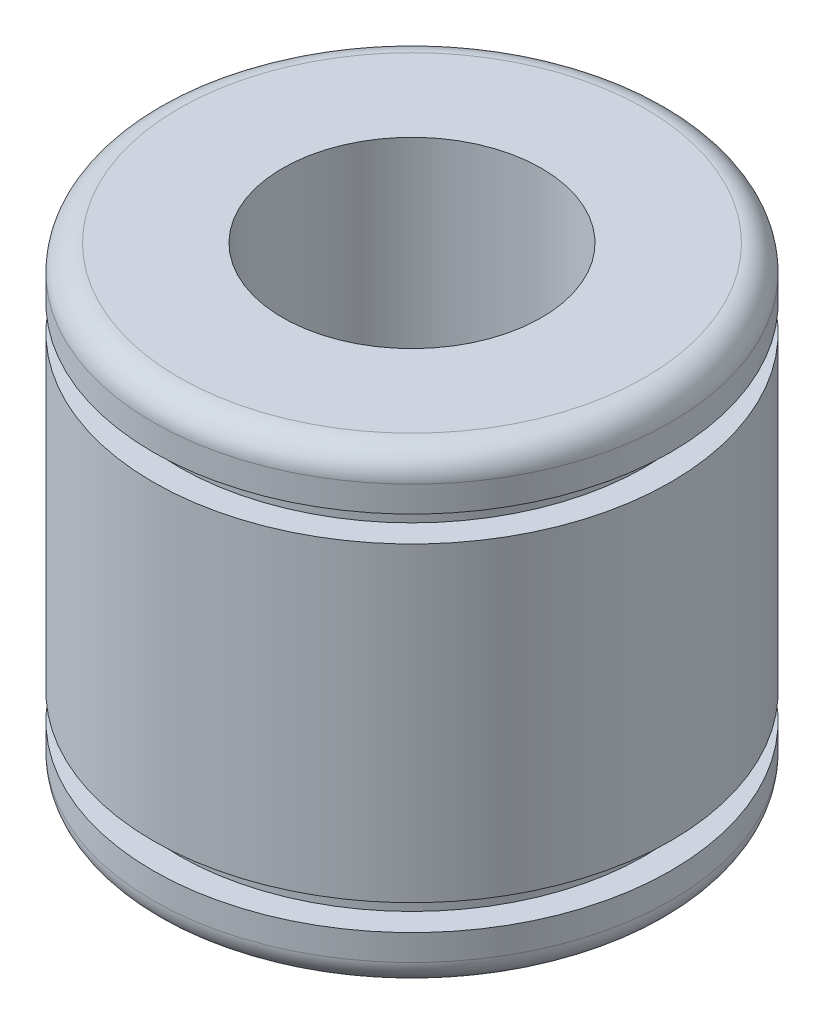
from build123d import *


with BuildPart() as part:
    # Esquisse1 → Révolution1 (revolve)
    with BuildSketch(Plane.XY, mode=Mode.PRIVATE) as r_volution1_sk:
        with BuildLine():
            Line((5, 3), (5, -3))
            Line((5, -3), (4.5, -3))
            Line((4.5, -3), (4.5, -3.5))
            Line((4.5, -3.5), (5, -3.5))
            Line((5, -3.5), (5, -4))
            ThreePointArc((5, -4), (4.853553391, -4.353553391), (4.5, -4.5))
            Line((4.5, -4.5), (2.5, -4.5))
            Line((2.5, -4.5), (2.5, 4.5))
            Line((2.5, 4.5), (4.5, 4.5))
            ThreePointArc((4.5, 4.5), (4.853553391, 4.353553391), (5, 4))
            Line((5, 4), (5, 3.5))
            Line((5, 3.5), (4.5, 3.5))
            Line((4.5, 3.5), (4.5, 3))
            Line((4.5, 3), (5, 3))
        make_face()
    revolve(r_volution1_sk.sketch.rotate(Axis((0, -18.848412698, 0), (0, 1, 0)), 90), axis=Axis((0, -18.848412698, 0), (0, 1, 0)))  # turned: the seam where the file's is


solid = part.part
